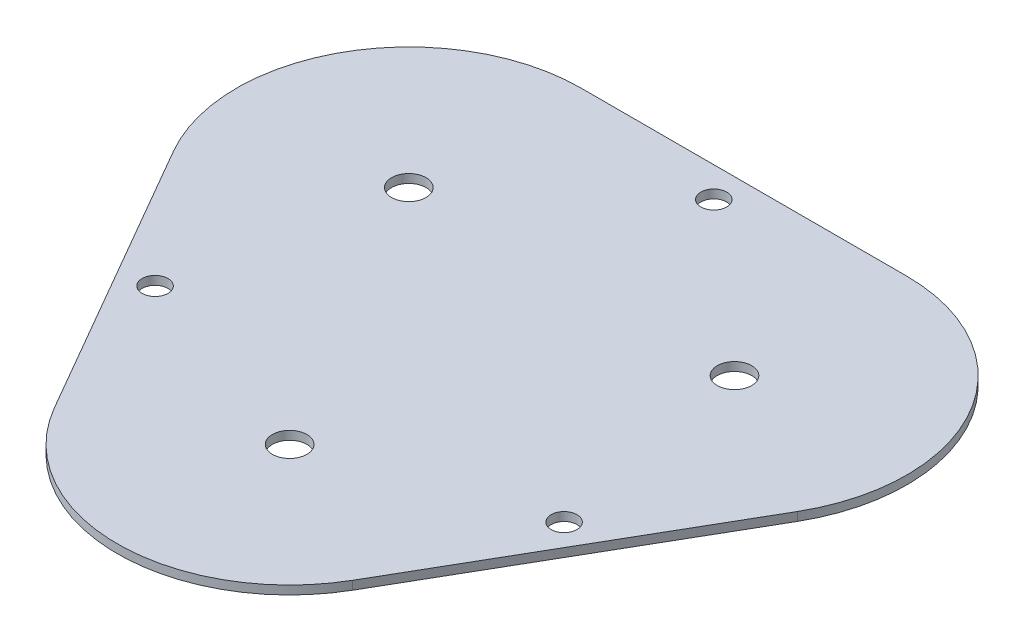
from build123d import *

# Parameters (mm, degrees)
SKETCH1_R           = 2
SKETCH1_R_2         = 1.5
BOSS_EXTRUDE1_DEPTH = 1
SKETCH2_W           = 5
SKETCH2_H           = 3
BOSS_EXTRUDE2_DEPTH = 4


with BuildPart() as part:
    # Sketch1 → Boss-Extrude1 (new body)
    with BuildSketch(Plane(origin=(0, 0, 0), x_dir=(1, 0, 0), z_dir=(0, 1, 0))):
        with BuildLine():
            Line((36.224008076, 0.913940814), (17.320508076, -31.827881627))
            ThreePointArc((17.320508076, -31.827881627), (0, -41.827881627), (-17.320508076, -31.827881627))
            Line((-17.320508076, -31.827881627), (-36.224008076, 0.913940814))
            ThreePointArc((-36.224008076, 0.913940814), (-36.224008076, 20.913940814), (-18.9035, 30.913940814))
            Line((-18.9035, 30.913940814), (18.9035, 30.913940814))
            ThreePointArc((18.9035, 30.913940814), (36.224008076, 20.913940814), (36.224008076, 0.913940814))
        make_face()
        with Locations((-18.9035, 10.913940814)):
            Circle(SKETCH1_R, mode=Mode.SUBTRACT)
        with Locations((18.9035, 10.913940814)):
            Circle(SKETCH1_R, mode=Mode.SUBTRACT)
        with Locations((0, -21.827881627)):
            Circle(SKETCH1_R, mode=Mode.SUBTRACT)
        with Locations((-23.741169162, -13.706970407)):
            Circle(SKETCH1_R_2, mode=Mode.SUBTRACT)
        with Locations((23.741169162, -13.706970407)):
            Circle(SKETCH1_R_2, mode=Mode.SUBTRACT)
        with Locations((0, 27.413940814)):
            Circle(SKETCH1_R_2, mode=Mode.SUBTRACT)
    extrude(amount=BOSS_EXTRUDE1_DEPTH)

    # Sketch2 → Boss-Extrude2 (add)
    with BuildSketch(Plane.XZ):
        Rectangle(SKETCH2_W, SKETCH2_H)
    extrude(amount=BOSS_EXTRUDE2_DEPTH)


solid = part.part
